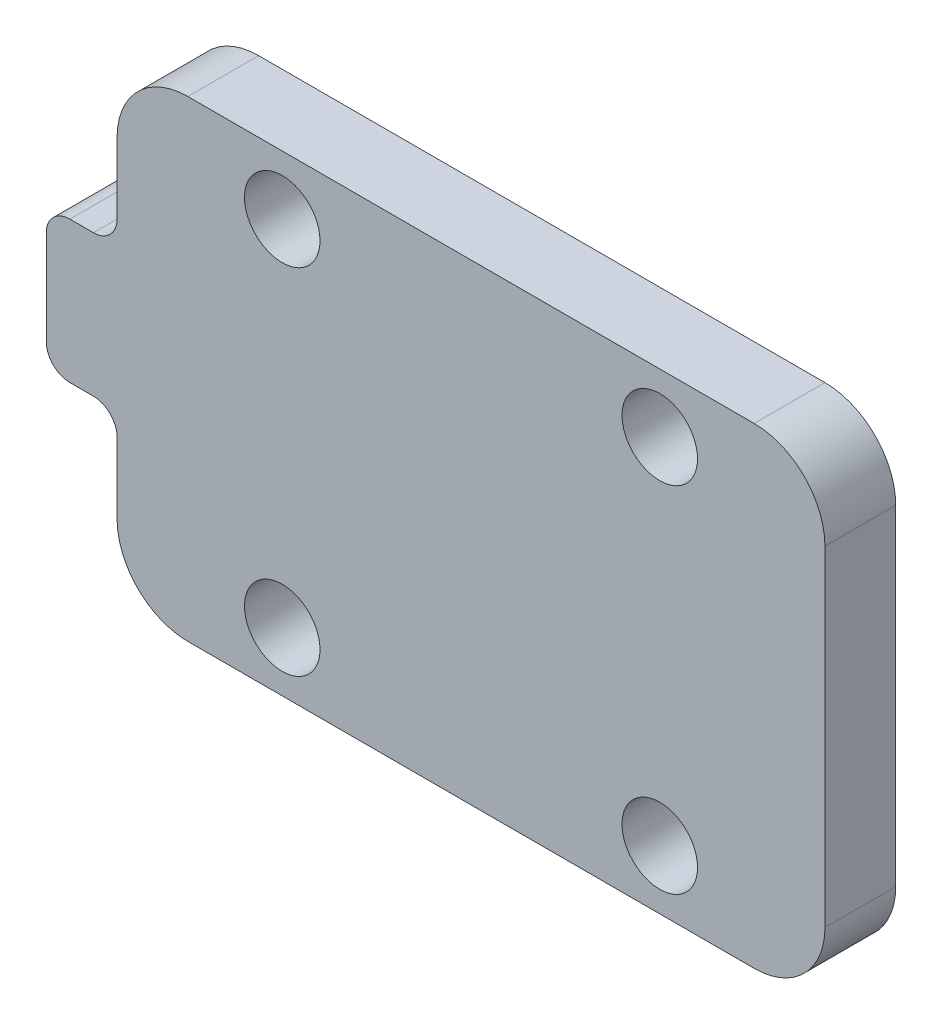
from build123d import *

# Parameters (mm, degrees)
SKETCH_2_W          = 30
SKETCH_2_H          = 20
EXTRUDE_1_DEPTH     = 3
FILLET_1_R          = 3
SKETCH_3_R          = 1.6
CUT_EXTRUDE_1_DEPTH = 4
EXTRUDE_2_DEPTH     = 3
FILLET_2_R          = 1


with BuildPart() as part:
    # 草图2 → 凸台-拉伸1 (new body)
    with BuildSketch(Plane.XY):
        with Locations((15, -10)):
            Rectangle(SKETCH_2_W, SKETCH_2_H)
    extrude(amount=EXTRUDE_1_DEPTH)

    # 圆角1
    fillet_1_edges = [part.edges().sort_by_distance(p)[0] for p in [
        (0, 0, 1.5),
        (30, 0, 1.5),
        (30, -20, 1.5),
        (0, -20, 1.5),
    ]]
    fillet(fillet_1_edges, radius=FILLET_1_R)

    # 草图3 → 切除-拉伸1 (cut, through all)
    with BuildSketch(Plane.XY.offset(3)):
        with Locations((23, -2.5)):
            Circle(SKETCH_3_R)
        with Locations((23, -17.5)):
            Circle(SKETCH_3_R)
        with Locations((7, -17.5)):
            Circle(SKETCH_3_R)
        with Locations((7, -2.5)):
            Circle(SKETCH_3_R)
    extrude(amount=-CUT_EXTRUDE_1_DEPTH, mode=Mode.SUBTRACT)

    # 草图4 → 凸台-拉伸2 (add)
    with BuildSketch(Plane(origin=(0, 0, 0), x_dir=(-1, 0, 0), z_dir=(0, 0, -1))):
        Polygon((0, -10), (0, -13), (3, -13), (3, -7), (0, -7), align=None)
    extrude(amount=-EXTRUDE_2_DEPTH)

    # 圆角2
    fillet_2_edges = [part.edges().sort_by_distance(p)[0] for p in [
        (0, -7, 1.5),
        (-3, -7, 1.5),
        (-3, -13, 1.5),
        (0, -13, 1.5),
    ]]
    fillet(fillet_2_edges, radius=FILLET_2_R)


solid = part.part
